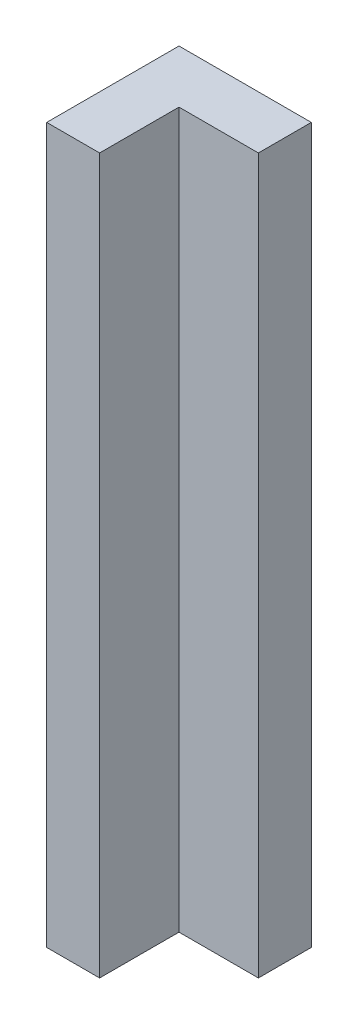
from build123d import *

# Parameters (mm, degrees)
BOSS_EXTRUDE1_DEPTH = 27


with BuildPart() as part:
    # Sketch1 → Boss-Extrude1 (new body)
    with BuildSketch(Plane(origin=(0, 0, 0), x_dir=(1, 0, 0), z_dir=(0, 1, 0))):
        Polygon((-6.432391634, 2.5), (-2.701042517, 2.5), (-2.701042517, 0.5), (-5.701042517, 0.5), (-5.701042517, -2.5), (-7.701042517, -2.5), (-7.701042517, 2.5), align=None)
    extrude(amount=BOSS_EXTRUDE1_DEPTH)


solid = part.part
